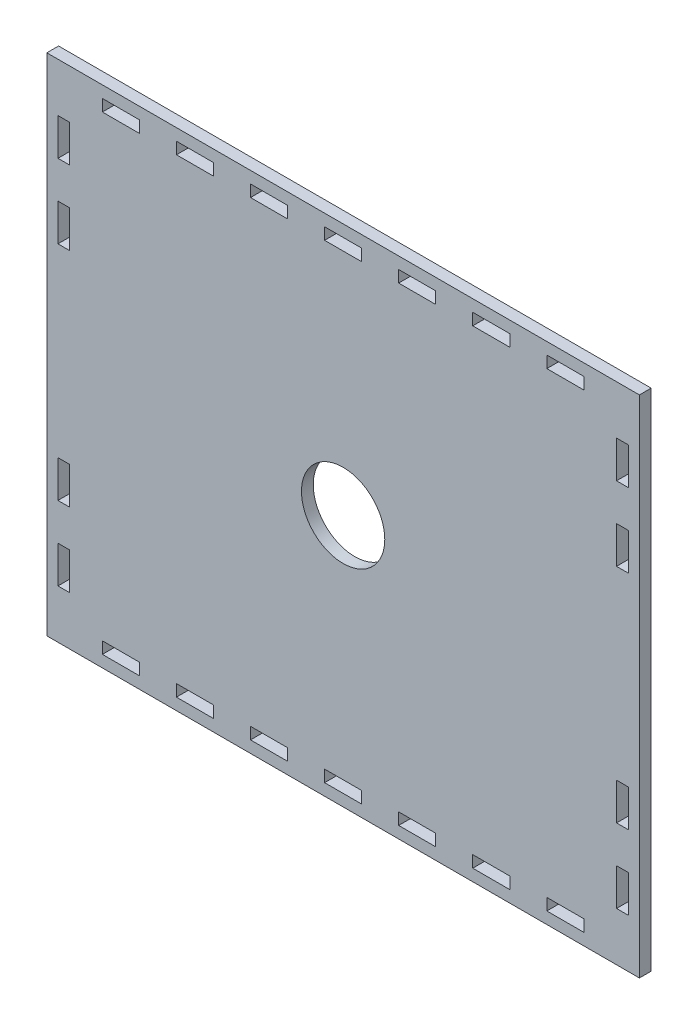
from build123d import *

# Parameters (mm, degrees)
SKETCH1_W           = 160
SKETCH1_H           = 136.35
SKETCH1_R           = 11.25
SKETCH1_W_2         = 10
SKETCH1_H_2         = 3.175
SKETCH1_W_3         = 3.175
SKETCH1_H_3         = 10
BOSS_EXTRUDE1_DEPTH = 3.175


with BuildPart() as part:
    # Sketch1 → Boss-Extrude1 (new body)
    with BuildSketch(Plane.XY):
        with Locations((80, 68.069958461)):
            Rectangle(SKETCH1_W, SKETCH1_H)
        with Locations((80, 68.069958461)):
            Circle(SKETCH1_R, mode=Mode.SUBTRACT)
        with Locations((40, 131.482458461)):
            Rectangle(SKETCH1_W_2, SKETCH1_H_2, mode=Mode.SUBTRACT)
        with Locations((20, 131.482458461)):
            Rectangle(SKETCH1_W_2, SKETCH1_H_2, mode=Mode.SUBTRACT)
        with Locations((60, 131.482458461)):
            Rectangle(SKETCH1_W_2, SKETCH1_H_2, mode=Mode.SUBTRACT)
        with Locations((80, 131.482458461)):
            Rectangle(SKETCH1_W_2, SKETCH1_H_2, mode=Mode.SUBTRACT)
        with Locations((100, 131.482458461)):
            Rectangle(SKETCH1_W_2, SKETCH1_H_2, mode=Mode.SUBTRACT)
        with Locations((120, 131.482458461)):
            Rectangle(SKETCH1_W_2, SKETCH1_H_2, mode=Mode.SUBTRACT)
        with Locations((140, 131.482458461)):
            Rectangle(SKETCH1_W_2, SKETCH1_H_2, mode=Mode.SUBTRACT)
        with Locations((140, 4.657458461)):
            Rectangle(SKETCH1_W_2, SKETCH1_H_2, mode=Mode.SUBTRACT)
        with Locations((120, 4.657458461)):
            Rectangle(SKETCH1_W_2, SKETCH1_H_2, mode=Mode.SUBTRACT)
        with Locations((100, 4.657458461)):
            Rectangle(SKETCH1_W_2, SKETCH1_H_2, mode=Mode.SUBTRACT)
        with Locations((80, 4.657458461)):
            Rectangle(SKETCH1_W_2, SKETCH1_H_2, mode=Mode.SUBTRACT)
        with Locations((60, 4.657458461)):
            Rectangle(SKETCH1_W_2, SKETCH1_H_2, mode=Mode.SUBTRACT)
        with Locations((40, 4.657458461)):
            Rectangle(SKETCH1_W_2, SKETCH1_H_2, mode=Mode.SUBTRACT)
        with Locations((20, 4.657458461)):
            Rectangle(SKETCH1_W_2, SKETCH1_H_2, mode=Mode.SUBTRACT)
        with Locations((4.5875, 38.069958461)):
            Rectangle(SKETCH1_W_3, SKETCH1_H_3, mode=Mode.SUBTRACT)
        with Locations((4.5875, 98.069958461)):
            Rectangle(SKETCH1_W_3, SKETCH1_H_3, mode=Mode.SUBTRACT)
        with Locations((4.5875, 118.069958461)):
            Rectangle(SKETCH1_W_3, SKETCH1_H_3, mode=Mode.SUBTRACT)
        with Locations((4.5875, 18.069958461)):
            Rectangle(SKETCH1_W_3, SKETCH1_H_3, mode=Mode.SUBTRACT)
        with Locations((155.4125, 18.069958461)):
            Rectangle(SKETCH1_W_3, SKETCH1_H_3, mode=Mode.SUBTRACT)
        with Locations((155.4125, 38.069958461)):
            Rectangle(SKETCH1_W_3, SKETCH1_H_3, mode=Mode.SUBTRACT)
        with Locations((155.4125, 98.069958461)):
            Rectangle(SKETCH1_W_3, SKETCH1_H_3, mode=Mode.SUBTRACT)
        with Locations((155.4125, 118.069958461)):
            Rectangle(SKETCH1_W_3, SKETCH1_H_3, mode=Mode.SUBTRACT)
    extrude(amount=BOSS_EXTRUDE1_DEPTH)


solid = part.part
